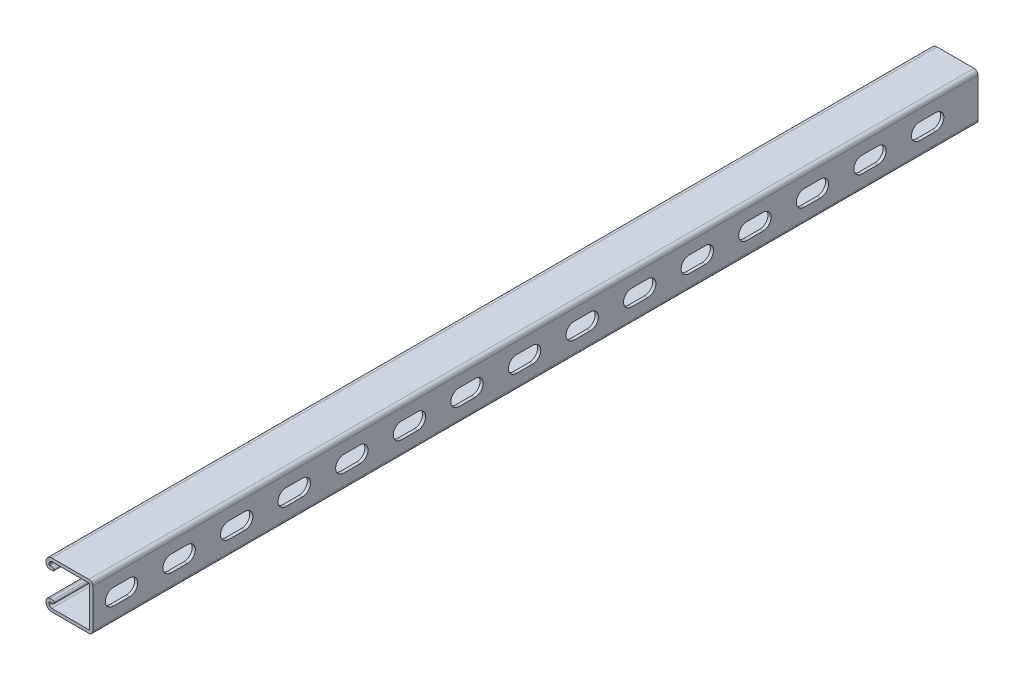
from build123d import *

# Parameters (mm, degrees)
BOSS_EXTRUDE1_DEPTH = 781.05
CUT_EXTRUDE1_DEPTH  = 2.794
LPATTERN1_COUNT     = 15
LPATTERN1_PITCH     = 50.8


with BuildPart() as part:
    # Sketch1 → Boss-Extrude1 (new body)
    with BuildSketch(Plane.XY):
        with BuildLine():
            Line((-36.22675, 20.6375), (-3.46075, 20.6375))
            ThreePointArc((-3.46075, 20.6375), (-1.013630207, 19.623869793), (0, 17.17675))
            Line((0, 17.17675), (0, -17.17675))
            ThreePointArc((0, -17.17675), (-1.013630207, -19.623869793), (-3.46075, -20.6375))
            Line((-3.46075, -20.6375), (-36.22675, -20.6375))
            ThreePointArc((-36.22675, -20.6375), (-39.796401808, -19.158901808), (-41.275, -15.58925))
            Line((-41.275, -15.58925), (-41.275, -14.57325))
            ThreePointArc((-41.275, -14.57325), (-40.261369793, -12.126130207), (-37.81425, -11.1125))
            Line((-37.81425, -11.1125), (-35.5346, -11.1125))
            ThreePointArc((-35.5346, -11.1125), (-34.1376, -12.5095), (-35.5346, -13.9065))
            Line((-35.5346, -13.9065), (-37.81425, -13.9065))
            ThreePointArc((-37.81425, -13.9065), (-38.285713446, -14.101786554), (-38.481, -14.57325))
            Line((-38.481, -14.57325), (-38.481, -15.58925))
            ThreePointArc((-38.481, -15.58925), (-37.820745461, -17.183245461), (-36.22675, -17.8435))
            Line((-36.22675, -17.8435), (-3.46075, -17.8435))
            ThreePointArc((-3.46075, -17.8435), (-2.989286554, -17.648213446), (-2.794, -17.17675))
            Line((-2.794, -17.17675), (-2.794, 17.17675))
            ThreePointArc((-2.794, 17.17675), (-2.989286554, 17.648213446), (-3.46075, 17.8435))
            Line((-3.46075, 17.8435), (-36.22675, 17.8435))
            ThreePointArc((-36.22675, 17.8435), (-37.820745461, 17.183245461), (-38.481, 15.58925))
            Line((-38.481, 15.58925), (-38.481, 14.57325))
            ThreePointArc((-38.481, 14.57325), (-38.285713446, 14.101786554), (-37.81425, 13.9065))
            Line((-37.81425, 13.9065), (-35.5346, 13.9065))
            ThreePointArc((-35.5346, 13.9065), (-34.1376, 12.5095), (-35.5346, 11.1125))
            Line((-35.5346, 11.1125), (-37.81425, 11.1125))
            ThreePointArc((-37.81425, 11.1125), (-40.261369793, 12.126130207), (-41.275, 14.57325))
            Line((-41.275, 14.57325), (-41.275, 15.58925))
            ThreePointArc((-41.275, 15.58925), (-39.796401808, 19.158901808), (-36.22675, 20.6375))
        make_face()
    extrude(amount=-BOSS_EXTRUDE1_DEPTH)

    # Sketch2 → Cut-Extrude1 (cut)
    with BuildSketch(Plane(origin=(0, 0, 0), x_dir=(0, 0, -1), z_dir=(1, 0, 0))):
        with BuildLine():
            Line((18.25625, 7.14375), (32.54375, 7.14375))
            ThreePointArc((32.54375, 7.14375), (39.6875, 0), (32.54375, -7.14375))
            Line((32.54375, -7.14375), (18.25625, -7.14375))
            ThreePointArc((18.25625, -7.14375), (11.1125, 0), (18.25625, 7.14375))
        make_face()
    cut_extrude1 = extrude(amount=-CUT_EXTRUDE1_DEPTH, mode=Mode.SUBTRACT)

    # LPattern1: Cut-Extrude1 ×15
    with Locations(*[(0, 0, -i * LPATTERN1_PITCH) for i in range(1, LPATTERN1_COUNT)]):
        add(cut_extrude1, mode=Mode.SUBTRACT)


solid = part.part
